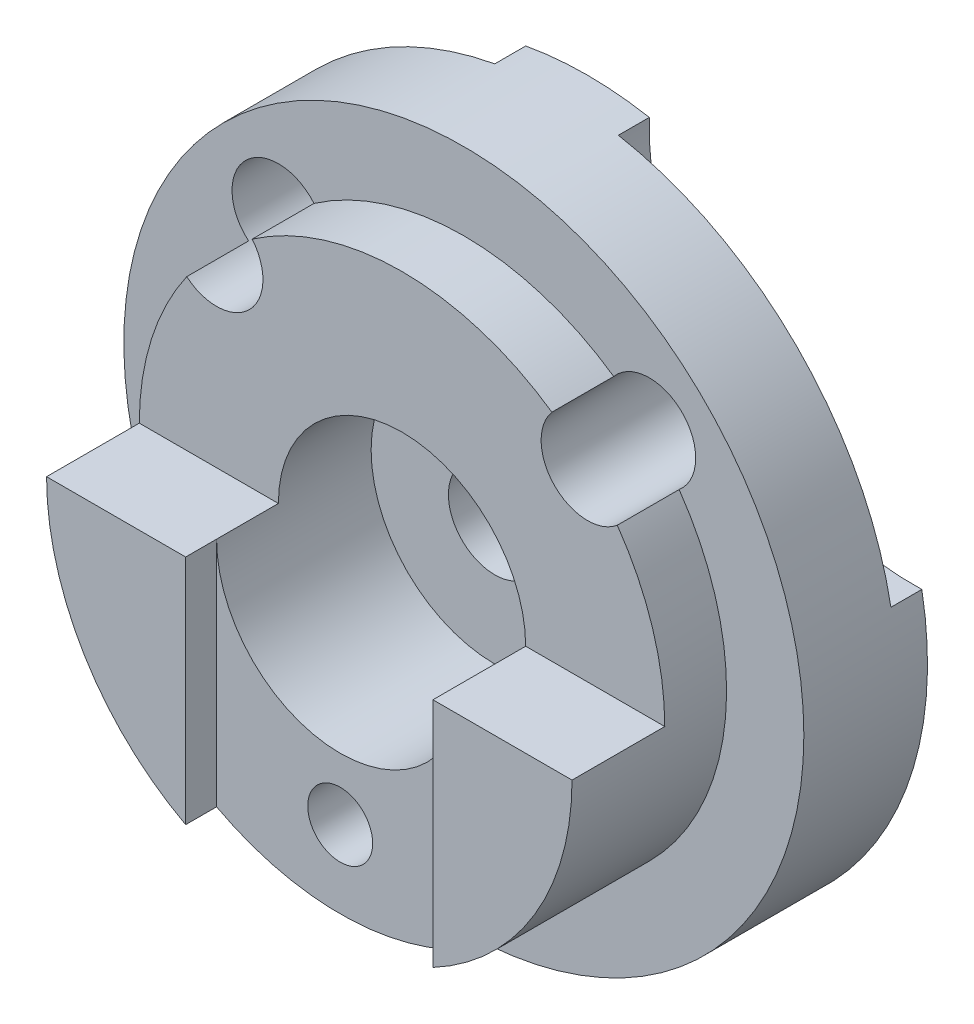
from build123d import *

# Parameters (mm, degrees)
BOSS_EXTRUDE1_DEPTH        = 15
SKETCH2_R                  = 42.5
BOSS_EXTRUDE2_DEPTH        = 10
CUT_EXTRUDE1_DEPTH         = 10
SKETCH4_R                  = 55
BOSS_EXTRUDE3_DEPTH        = 15
SKETCH5_R                  = 42.5
CUT_EXTRUDE16_DEPTH        = 5
BOSS_EXTRUDE4_DEPTH        = 10
SKETCH11_R                 = 20
SKETCH11_R_2               = 7.5
CUT_EXTRUDE18_DEPTH        = 20
SKETCH13_R                 = 2.5
CUT_EXTRUDE19_DEPTH        = 15
SKETCH14_R                 = 7.5
CUT_EXTRUDE20_DEPTH        = 20
CUT_EXTRUDE21_DEPTH        = 20
SKETCH23_R                 = 55
BOSS_EXTRUDE5_DEPTH        = 10
SKETCH24_R                 = 55
BOSS_EXTRUDE6_DEPTH        = 10
SKETCH25_W                 = 15
SKETCH25_H                 = 55
CUT_EXTRUDE22_DEPTH        = 70
SKETCH26_R                 = 7.5
CUT_EXTRUDE23_DEPTH        = 140
CUT_EXTRUDE24_DEPTH        = 140
SKETCH29_R                 = 20
CUT_EXTRUDE25_DEPTH        = 10
CUT_EXTRUDE28_DEPTH        = 10
BOSS_EXTRUDE8_DEPTH        = 5
M12X1_5_TAPPED_HOLE1_D     = 10.5
M12X1_5_TAPPED_HOLE1_DEPTH = 10
M12X1_5_TAPPED_HOLE1_TIP   = 3.15451825
SKETCH37_W                 = 12.5
SKETCH37_H                 = 25
CUT_EXTRUDE29_DEPTH        = 75
CUT_EXTRUDE30_DEPTH        = 20
SKETCH39_R                 = 2.5
CUT_EXTRUDE31_DEPTH        = 20
SKETCH41_R                 = 5.25
BOSS_EXTRUDE17_DEPTH       = 5


with BuildPart() as part:
    # Sketch1 → Boss-Extrude1 (new body)
    with BuildSketch(Plane.XY):
        with BuildLine():
            ThreePointArc((-55, 0), (0, -55), (55, 0))
            ThreePointArc((55, 0), (23.180194847, 13.180194847), (10, 45))
            ThreePointArc((10, 45), (0, 45.916730868), (-10, 45))
            ThreePointArc((-10, 45), (-23.180194847, 13.180194847), (-55, 0))
        make_face()
    extrude(amount=BOSS_EXTRUDE1_DEPTH)

    # Sketch2 → Boss-Extrude2 (add)
    with BuildSketch(Plane.XY.offset(15)):
        Circle(SKETCH2_R)
    extrude(amount=BOSS_EXTRUDE2_DEPTH)

    # Sketch3 → Cut-Extrude1 (cut)
    with BuildSketch(Plane.XY.offset(25)):
        with BuildLine():
            ThreePointArc((-36.280461431, 22.13544936), (-23.020695518, 22.941176471), (-22.260854774, 36.203650986))
            ThreePointArc((-22.260854774, 36.203650986), (-30.103986447, 30), (-36.280461431, 22.13544936))
        make_face()
        with BuildLine():
            ThreePointArc((22.260854774, 36.203650986), (23.020695518, 22.941176471), (36.280461431, 22.13544936))
            ThreePointArc((36.280461431, 22.13544936), (30.103986447, 30), (22.260854774, 36.203650986))
        make_face()
    extrude(amount=-CUT_EXTRUDE1_DEPTH, mode=Mode.SUBTRACT)

    # Sketch4 → Boss-Extrude3 (add)
    with BuildSketch(Plane.XY.offset(25)):
        Circle(SKETCH4_R)
    extrude(amount=BOSS_EXTRUDE3_DEPTH)

    # Sketch5 → Cut-Extrude16 (cut)
    with BuildSketch(Plane.XY.offset(40)):
        Circle(SKETCH5_R)
    extrude(amount=-CUT_EXTRUDE16_DEPTH, mode=Mode.SUBTRACT)

    # Sketch10 → Boss-Extrude4 (add)
    with BuildSketch(Plane.XY.offset(35)):
        with BuildLine():
            Line((-20, -37.5), (-20, 0))
            Line((-20, 0), (-42.5, 0))
            ThreePointArc((-42.5, 0), (-36.443449343, -21.866069606), (-20, -37.5))
        make_face()
        with BuildLine():
            Line((42.5, 0), (20, 0))
            Line((20, 0), (20, -37.5))
            ThreePointArc((20, -37.5), (36.443449343, -21.866069606), (42.5, 0))
        make_face()
    extrude(amount=BOSS_EXTRUDE4_DEPTH)

    # Sketch11 → Cut-Extrude18 (cut)
    with BuildSketch(Plane.XY.offset(35)):
        Circle(SKETCH11_R)
        Circle(SKETCH11_R_2, mode=Mode.SUBTRACT)
    extrude(amount=-CUT_EXTRUDE18_DEPTH, mode=Mode.SUBTRACT)

    # Sketch13 → Cut-Extrude19 (cut)
    with BuildSketch(Plane.XY.offset(40)):
        with Locations((0, -50)):
            Circle(SKETCH13_R)
    extrude(amount=-CUT_EXTRUDE19_DEPTH, mode=Mode.SUBTRACT)

    # Sketch14 → Cut-Extrude20 (cut)
    with BuildSketch(Plane.XY.offset(35)):
        with Locations((-30, 30.103986447)):
            Circle(SKETCH14_R)
        with Locations((30, 30.103986447)):
            Circle(SKETCH14_R)
    extrude(amount=-CUT_EXTRUDE20_DEPTH, mode=Mode.SUBTRACT)

    # Sketch16 → Cut-Extrude21 (cut)
    with BuildSketch(Plane.XY.offset(40)):
        with BuildLine():
            ThreePointArc((-34.824619737, 24.361770464), (-26.832560027, 23.305654003), (-22.5, 30.103986447))
            ThreePointArc((-22.5, 30.103986447), (-22.948703366, 32.659219465), (-24.241124207, 34.908708042))
            ThreePointArc((-24.241124207, 34.908708042), (-30, 30.103986447), (-34.824619737, 24.361770464))
        make_face()
        with BuildLine():
            ThreePointArc((-34.824619737, 24.361770464), (-30, 30.103986447), (-24.241124207, 34.908708042))
            ThreePointArc((-24.241124207, 34.908708042), (-35.294117647, 35.416454644), (-34.824619737, 24.361770464))
        make_face()
        with BuildLine():
            ThreePointArc((37.5, 30.103986447), (32.555233018, 37.155283081), (24.241124207, 34.908708042))
            ThreePointArc((24.241124207, 34.908708042), (30, 30.103986447), (34.824619737, 24.361770464))
            ThreePointArc((34.824619737, 24.361770464), (36.798332444, 26.936546474), (37.5, 30.103986447))
        make_face()
        with BuildLine():
            ThreePointArc((34.824619737, 24.361770464), (30, 30.103986447), (24.241124207, 34.908708042))
            ThreePointArc((24.241124207, 34.908708042), (24.705882353, 24.79151825), (34.824619737, 24.361770464))
        make_face()
    extrude(amount=-CUT_EXTRUDE21_DEPTH, mode=Mode.SUBTRACT)

    # Sketch23 → Boss-Extrude5 (add)
    with BuildSketch(Plane(origin=(0, 0, 15), x_dir=(-1, 0, 0), z_dir=(0, 0, -1))):
        Circle(SKETCH23_R)
    extrude(amount=BOSS_EXTRUDE5_DEPTH)

    # Sketch24 → Boss-Extrude6 (add)
    with BuildSketch(Plane.XY.offset(15)):
        Circle(SKETCH24_R)
    extrude(amount=BOSS_EXTRUDE6_DEPTH)

    # Sketch25 → Cut-Extrude22 (cut, symmetric)
    with BuildSketch(Plane(origin=(0, 0, 0), x_dir=(0, 0, -1), z_dir=(1, 0, 0))):
        with Locations((-37.5, 27.5)):
            Rectangle(SKETCH25_W, SKETCH25_H)
    extrude(amount=CUT_EXTRUDE22_DEPTH, both=True, mode=Mode.SUBTRACT)

    # Sketch26 → Cut-Extrude23 (cut)
    with BuildSketch(Plane.XY.offset(25)):
        with Locations((30, 30.103986447)):
            Circle(SKETCH26_R)
        with Locations((-30, 30.103986447)):
            Circle(SKETCH26_R)
    extrude(amount=-CUT_EXTRUDE23_DEPTH, mode=Mode.SUBTRACT)

    # Sketch27 → Cut-Extrude24 (cut)
    with BuildSketch(Plane.XY.offset(35)):
        with BuildLine():
            ThreePointArc((-7.5, 0), (0, -7.5), (7.5, 0))
            Line((7.5, 0), (-7.5, 0))
        make_face()
        with BuildLine():
            ThreePointArc((7.5, 0), (0, 7.5), (-7.5, 0))
            Line((-7.5, 0), (7.5, 0))
        make_face()
    extrude(amount=-CUT_EXTRUDE24_DEPTH, mode=Mode.SUBTRACT)

    # Sketch29 → Cut-Extrude25 (cut)
    with BuildSketch(Plane.XY.offset(25)):
        Circle(SKETCH29_R)
    extrude(amount=-CUT_EXTRUDE25_DEPTH, mode=Mode.SUBTRACT)

    # Sketch33 → Cut-Extrude28 (cut)
    with BuildSketch(Plane.XY.offset(30)):
        with BuildLine():
            ThreePointArc((55, 0), (0, 55), (-55, 0))
            Line((-55, 0), (-42.5, 0))
            ThreePointArc((-42.5, 0), (-40.535764078, 12.771132706), (-34.824619737, 24.361770464))
            ThreePointArc((-34.824619737, 24.361770464), (-35.294117647, 35.416454644), (-24.241124207, 34.908708042))
            ThreePointArc((-24.241124207, 34.908708042), (0, 42.5), (24.241124207, 34.908708042))
            ThreePointArc((24.241124207, 34.908708042), (32.555233018, 37.155283081), (37.5, 30.103986447))
            ThreePointArc((37.5, 30.103986447), (36.798332444, 26.936546474), (34.824619737, 24.361770464))
            ThreePointArc((34.824619737, 24.361770464), (40.535764078, 12.771132706), (42.5, 0))
            Line((42.5, 0), (55, 0))
        make_face()
    extrude(amount=-CUT_EXTRUDE28_DEPTH, mode=Mode.SUBTRACT)

    # Sketch34 → Boss-Extrude8 (add)
    with BuildSketch(Plane(origin=(0, 0, 5), x_dir=(-1, 0, 0), z_dir=(0, 0, -1))):
        with BuildLine():
            ThreePointArc((-10, 54.083269132), (-22.5, 22.5), (-54.083269132, 10))
            ThreePointArc((-54.083269132, 10), (-54.770337785, 5.02096593), (-55, 0))
            ThreePointArc((-55, 0), (-23.180194847, 13.180194847), (-10, 45))
            ThreePointArc((-10, 45), (0, 45.916730868), (10, 45))
            ThreePointArc((10, 45), (23.180194847, 13.180194847), (55, 0))
            ThreePointArc((55, 0), (54.770337785, 5.02096593), (54.083269132, 10))
            ThreePointArc((54.083269132, 10), (22.5, 22.5), (10, 54.083269132))
            ThreePointArc((10, 54.083269132), (0, 55), (-10, 54.083269132))
        make_face()
    extrude(amount=BOSS_EXTRUDE8_DEPTH)

    # M12x1.5 Tapped Hole1
    with Locations(Plane(origin=(0, -30, 35), x_dir=(1, 0, 0), z_dir=(0, 0, 1))):
        with Locations((0, 0)):
            Hole(M12X1_5_TAPPED_HOLE1_D / 2, depth=M12X1_5_TAPPED_HOLE1_DEPTH)
            with Locations((0, 0, -(M12X1_5_TAPPED_HOLE1_DEPTH + M12X1_5_TAPPED_HOLE1_TIP / 2))):  # 118° drill point
                Cone(0, M12X1_5_TAPPED_HOLE1_D / 2, M12X1_5_TAPPED_HOLE1_TIP, mode=Mode.SUBTRACT)

    # Sketch37 → Cut-Extrude29 (cut)
    with BuildSketch(Plane(origin=(0, 0, 0), x_dir=(1, 0, 0), z_dir=(0, 1, 0))):
        with Locations((-48.75, -32.5)):
            Rectangle(SKETCH37_W, SKETCH37_H)
        with Locations((48.75, -32.5)):
            Rectangle(SKETCH37_W, SKETCH37_H)
    extrude(amount=-CUT_EXTRUDE29_DEPTH, mode=Mode.SUBTRACT)

    # Sketch38 → Cut-Extrude30 (cut)
    with BuildSketch(Plane.XY.offset(40)):
        with BuildLine():
            Line((-42.5, 0), (-42.5, -34.910600109))
            ThreePointArc((-42.5, -34.910600109), (0, -55), (42.5, -34.910600109))
            Line((42.5, -34.910600109), (42.5, 0))
            ThreePointArc((42.5, 0), (36.443449343, -21.866069606), (20, -37.5))
            ThreePointArc((20, -37.5), (0, -42.5), (-20, -37.5))
            ThreePointArc((-20, -37.5), (-36.443449343, -21.866069606), (-42.5, 0))
        make_face()
    extrude(amount=-CUT_EXTRUDE30_DEPTH, mode=Mode.SUBTRACT)

    # Sketch39 → Cut-Extrude31 (cut)
    with BuildSketch(Plane.XY.offset(20)):
        with Locations((0, -50)):
            Circle(SKETCH39_R)
    extrude(amount=-CUT_EXTRUDE31_DEPTH, mode=Mode.SUBTRACT)

    # Sketch41 → Boss-Extrude17 (add)
    with BuildSketch(Plane.XY.offset(35)):
        with BuildLine():
            Line((-20, 0), (-20, -37.5))
            ThreePointArc((-20, -37.5), (0, -42.5), (20, -37.5))
            Line((20, -37.5), (20, 0))
            ThreePointArc((20, 0), (0, -20), (-20, 0))
        make_face()
        with Locations((0, -30)):
            Circle(SKETCH41_R, mode=Mode.SUBTRACT)
    extrude(amount=BOSS_EXTRUDE17_DEPTH)


solid = part.part
